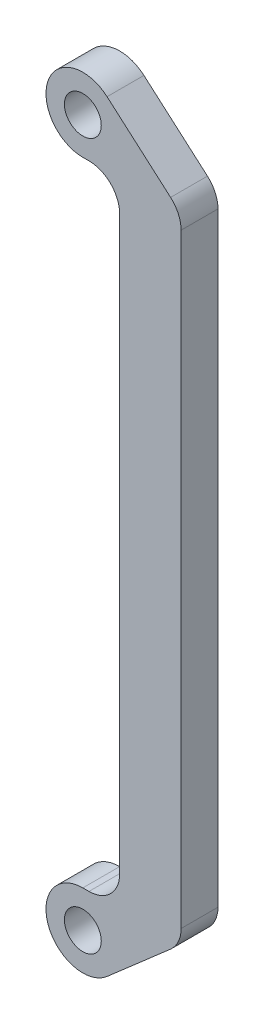
from build123d import *

# Parameters (mm, degrees)
CROQUIS1_R              = 3
CROQUIS1_R_2            = 6
SALIENTE_EXTRUIR1_DEPTH = 6


with BuildPart() as part:
    # Croquis1 → Saliente-Extruir1 (new body)
    with BuildSketch(Plane.XY):
        with BuildLine():
            ThreePointArc((0, -6), (2.10674065, -5.617975065), (3.945205479, -4.520547945))
            ThreePointArc((3.945205479, -4.520547945), (5.462198865, -2.482817666), (6, 0))
            ThreePointArc((6, 0), (4.242640687, 4.242640687), (0, 6))
            ThreePointArc((0, 6), (-4.242640687, 4.242640687), (-6, 0))
            ThreePointArc((-6, 0), (-4.242640687, -4.242640687), (0, -6))
        make_face()
        Circle(CROQUIS1_R, mode=Mode.SUBTRACT)
        with BuildLine():
            ThreePointArc((14.287671233, 4.505603985), (15.551832387, 6.203712551), (16, 8.272727273))
            Line((16, 8.272727273), (16, 106.727272727))
            ThreePointArc((16, 106.727272727), (15.551832387, 108.796287449), (14.287671233, 110.494396015))
            Line((14.287671233, 110.494396015), (3.945205479, 119.520547945))
            ThreePointArc((3.945205479, 119.520547945), (5.462198865, 117.482817666), (6, 115))
            ThreePointArc((6, 115), (4.242640687, 110.757359313), (0, 109))
            Line((0, 109), (1, 109))
            ThreePointArc((1, 109), (4.535533906, 107.535533906), (6, 104))
            Line((6, 104), (6, 11))
            ThreePointArc((6, 11), (4.535533906, 7.464466094), (1, 6))
            Line((1, 6), (0, 6))
            ThreePointArc((0, 6), (4.242640687, 4.242640687), (6, 0))
            ThreePointArc((6, 0), (5.462198865, -2.482817666), (3.945205479, -4.520547945))
            Line((3.945205479, -4.520547945), (14.287671233, 4.505603985))
        make_face()
        with Locations((0, 115)):
            Circle(CROQUIS1_R_2)
        with Locations((0, 115)):
            Circle(CROQUIS1_R, mode=Mode.SUBTRACT)
    extrude(amount=SALIENTE_EXTRUIR1_DEPTH)


solid = part.part
